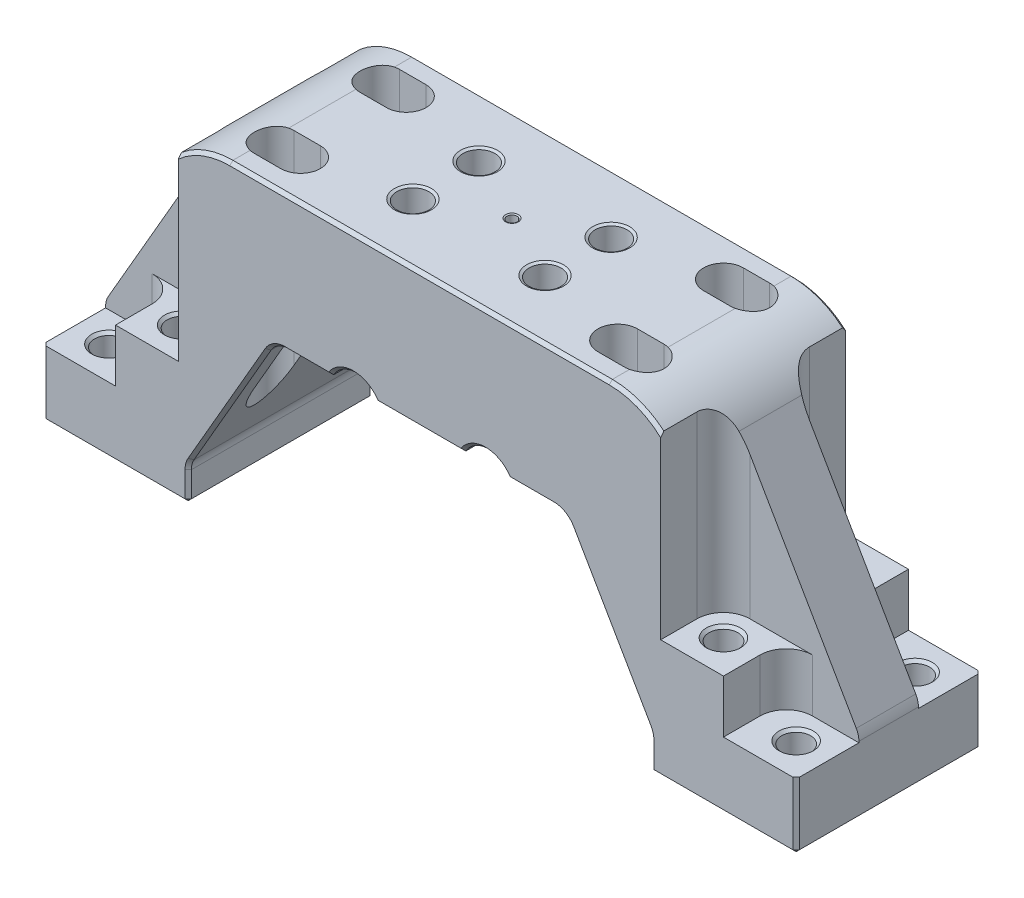
from build123d import *

# Parameters (mm, degrees)
EXTRUDE1_DEPTH                              = 44.45
FILLET1_R                                   = 38.1
FILLET2_R                                   = 9.525
FILLET5_R                                   = 9.525
EXTRUDE2_DEPTH                              = 25.4
FILLET3_R                                   = 3.175
EXTRUDE3_DEPTH                              = 95.25
EXTRUDE4_DEPTH                              = 25.4
F_1_2_CLEARANCE_HOLE1_AT_2_COUNT            = 2
F_1_2_CLEARANCE_HOLE1_AT_2_PITCH            = 260.35
F_1_2_CLEARANCE_HOLE1_AT_3_COUNT            = 2
F_1_2_CLEARANCE_HOLE1_AT_3_PITCH            = 266.548766645
F_1_2_CLEARANCE_HOLE1_AT_4_COUNT            = 2
F_1_2_CLEARANCE_HOLE1_AT_4_PITCH            = 57.15
F_1_2_CLEARANCE_HOLE2_AT_2_COUNT            = 2
F_1_2_CLEARANCE_HOLE2_AT_2_PITCH            = 57.15
F_1_2_CLEARANCE_HOLE2_AT_3_COUNT            = 2
F_1_2_CLEARANCE_HOLE2_AT_3_PITCH            = 335.10917997
F_1_2_CLEARANCE_HOLE2_AT_4_COUNT            = 2
F_1_2_CLEARANCE_HOLE2_AT_4_PITCH            = 330.2
TAPPED_HOLE_FOR_1_2_13_HELICOIL1_AT_2_COUNT = 2
TAPPED_HOLE_FOR_1_2_13_HELICOIL1_AT_2_PITCH = 63.5
TAPPED_HOLE_FOR_1_2_13_HELICOIL1_AT_3_COUNT = 2
TAPPED_HOLE_FOR_1_2_13_HELICOIL1_AT_3_PITCH = 70.995158286
TAPPED_HOLE_FOR_1_2_13_HELICOIL1_AT_4_COUNT = 2
TAPPED_HOLE_FOR_1_2_13_HELICOIL1_AT_4_PITCH = 31.75
EXTRUDE5_DEPTH                              = 153.4
SKETCH12_R                                  = 12.7
EXTRUDE6_DEPTH                              = 45.4500001
EXTRUDE6_DEPTH_BACK                         = 45.4500001
CHAMFER1_SIZE                               = 1.524


with BuildPart() as part:
    # Sketch1 → Extrude1 (new body, symmetric)
    with BuildSketch(Plane.XY):
        Polygon((-180.975, 0), (-111.125, 0), (-111.125, 16.208748909), (-70.036568425, 87.376), (70.036568425, 87.376), (111.125, 16.208748909), (111.125, 0), (180.975, 0), (180.975, 34.925), (113.150777127, 152.4), (-113.150777127, 152.4), (-180.975, 34.925), align=None)
    extrude(amount=EXTRUDE1_DEPTH, both=True)

    # Fillet1
    fillet1_edges = [part.edges().sort_by_distance(p)[0] for p in [
        (-113.150777127, 152.4, 0),
        (113.150777127, 152.4, 0),
    ]]
    fillet(fillet1_edges, radius=FILLET1_R)

    # Fillet2
    fillet2_edges = [part.edges().sort_by_distance(p)[0] for p in [
        (111.125, 16.208748909, 0),
        (70.036568425, 87.376, 0),
        (-70.036568425, 87.376, 0),
        (-111.125, 16.208748909, 0),
    ]]
    fillet(fillet2_edges, radius=FILLET2_R)

    # Fillet5
    fillet5_edges = [part.edges().sort_by_distance(p)[0] for p in [
        (-180.975, 34.925, 0),
        (180.975, 34.925, 0),
    ]]
    fillet(fillet5_edges, radius=FILLET5_R)

    # Sketch2 → Extrude2 (cut)
    with BuildSketch(Plane.XZ.offset(-87.376)):
        with BuildLine():
            Line((-47.625, 31.75), (47.625, 31.75))
            ThreePointArc((47.625, 31.75), (56.605256121, 28.030256121), (60.325, 19.05))
            Line((60.325, 19.05), (60.325, -19.05))
            ThreePointArc((60.325, -19.05), (56.605256121, -28.030256121), (47.625, -31.75))
            Line((47.625, -31.75), (-47.625, -31.75))
            ThreePointArc((-47.625, -31.75), (-56.605256121, -28.030256121), (-60.325, -19.05))
            Line((-60.325, -19.05), (-60.325, 19.05))
            ThreePointArc((-60.325, 19.05), (-56.605256121, 28.030256121), (-47.625, 31.75))
        make_face()
    extrude(amount=-EXTRUDE2_DEPTH, mode=Mode.SUBTRACT)

    # Fillet3
    fillet3_edges = [part.edges().sort_by_distance(p)[0] for p in [
        (-56.605256121, 112.776, 28.030256121),
        (0, 112.776, 31.75),
        (56.605256121, 112.776, 28.030256121),
        (60.325, 112.776, 0),
        (56.605256121, 112.776, -28.030256121),
        (0, 112.776, -31.75),
        (-56.605256121, 112.776, -28.030256121),
        (-60.325, 112.776, 0),
    ]]
    fillet(fillet3_edges, radius=FILLET3_R)

    # Sketch3 → Extrude3 (cut)
    with BuildSketch(Plane(origin=(0, 152.4, 0), x_dir=(1, 0, 0), z_dir=(0, 1, 0))):
        with BuildLine():
            Line((115.8875, 44.45), (180.975, 44.45))
            Line((180.975, 44.45), (180.975, 14.2875))
            Line((180.975, 14.2875), (128.5875, 14.2875))
            ThreePointArc((128.5875, 14.2875), (119.607243879, 18.007243879), (115.8875, 26.9875))
            Line((115.8875, 26.9875), (115.8875, 44.45))
        make_face()
        with BuildLine():
            Line((180.975, -44.45), (180.975, -14.2875))
            Line((180.975, -14.2875), (128.5875, -14.2875))
            ThreePointArc((128.5875, -14.2875), (119.607243879, -18.007243879), (115.8875, -26.9875))
            Line((115.8875, -26.9875), (115.8875, -44.45))
            Line((115.8875, -44.45), (180.975, -44.45))
        make_face()
        with BuildLine():
            Line((-115.8875, -44.45), (-180.975, -44.45))
            Line((-180.975, -44.45), (-180.975, -14.2875))
            Line((-180.975, -14.2875), (-128.5875, -14.2875))
            ThreePointArc((-128.5875, -14.2875), (-119.607243879, -18.007243879), (-115.8875, -26.9875))
            Line((-115.8875, -26.9875), (-115.8875, -44.45))
        make_face()
        with BuildLine():
            Line((-180.975, 44.45), (-180.975, 14.2875))
            Line((-180.975, 14.2875), (-128.5875, 14.2875))
            ThreePointArc((-128.5875, 14.2875), (-119.607243879, 18.007243879), (-115.8875, 26.9875))
            Line((-115.8875, 26.9875), (-115.8875, 44.45))
            Line((-115.8875, 44.45), (-180.975, 44.45))
        make_face()
    extrude(amount=-EXTRUDE3_DEPTH, mode=Mode.SUBTRACT)

    # Sketch4 → Extrude4 (cut)
    with BuildSketch(Plane(origin=(0, 57.15, 0), x_dir=(1, 0, 0), z_dir=(0, 1, 0))):
        with BuildLine():
            Line((180.975, 44.45), (146.05, 44.45))
            Line((146.05, 44.45), (146.05, 26.9875))
            ThreePointArc((146.05, 26.9875), (149.769743879, 18.007243879), (158.75, 14.2875))
            Line((158.75, 14.2875), (180.975, 14.2875))
            Line((180.975, 14.2875), (180.975, 44.45))
        make_face()
        with BuildLine():
            Line((146.05, -44.45), (146.05, -26.9875))
            ThreePointArc((146.05, -26.9875), (149.769743879, -18.007243879), (158.75, -14.2875))
            Line((158.75, -14.2875), (180.975, -14.2875))
            Line((180.975, -14.2875), (180.975, -44.45))
            Line((180.975, -44.45), (146.05, -44.45))
        make_face()
        with BuildLine():
            Line((-180.975, -44.45), (-146.05, -44.45))
            Line((-146.05, -44.45), (-146.05, -26.9875))
            ThreePointArc((-146.05, -26.9875), (-149.769743879, -18.007243879), (-158.75, -14.2875))
            Line((-158.75, -14.2875), (-180.975, -14.2875))
            Line((-180.975, -14.2875), (-180.975, -44.45))
        make_face()
        with BuildLine():
            Line((-146.05, 44.45), (-146.05, 26.9875))
            ThreePointArc((-146.05, 26.9875), (-149.769743879, 18.007243879), (-158.75, 14.2875))
            Line((-158.75, 14.2875), (-180.975, 14.2875))
            Line((-180.975, 14.2875), (-180.975, 44.45))
            Line((-180.975, 44.45), (-146.05, 44.45))
        make_face()
    extrude(amount=-EXTRUDE4_DEPTH, mode=Mode.SUBTRACT)

    # Sketch5 → 1/2 Clearance Hole1 (revolve, cut)
    with BuildSketch(Plane(origin=(130.175, 57.15, -28.575), x_dir=(0, 0, 1), z_dir=(1, 0, 0))):
        Polygon((0, 0), (0, 57.15), (8.255, 57.15), (6.94563, 55.84063), (6.94563, 1.30937), (8.255, 0), align=None)
    f_1_2_clearance_hole1 = revolve(axis=Axis((130.175, 63.5, -28.575), (0, -1, 0)), mode=Mode.SUBTRACT)

    # 1/2 Clearance Hole1 at 2: 1/2 Clearance Hole1 ×2
    with Locations(*[(-i * F_1_2_CLEARANCE_HOLE1_AT_2_PITCH, 0, 0) for i in range(1, F_1_2_CLEARANCE_HOLE1_AT_2_COUNT)]):
        add(f_1_2_clearance_hole1, mode=Mode.SUBTRACT)

    # 1/2 Clearance Hole1 at 3: 1/2 Clearance Hole1 ×2
    with Locations(*[Vector(-0.976744343, 0, 0.214407295) * (i * F_1_2_CLEARANCE_HOLE1_AT_3_PITCH) for i in range(1, F_1_2_CLEARANCE_HOLE1_AT_3_COUNT)]):
        add(f_1_2_clearance_hole1, mode=Mode.SUBTRACT)

    # 1/2 Clearance Hole1 at 4: 1/2 Clearance Hole1 ×2
    with Locations(*[(0, 0, i * F_1_2_CLEARANCE_HOLE1_AT_4_PITCH) for i in range(1, F_1_2_CLEARANCE_HOLE1_AT_4_COUNT)]):
        add(f_1_2_clearance_hole1, mode=Mode.SUBTRACT)

    # Sketch7 → 1/2 Clearance Hole2 (revolve, cut)
    with BuildSketch(Plane(origin=(165.1, 31.75, -28.575), x_dir=(0, 0, 1), z_dir=(1, 0, 0))):
        Polygon((0, 0), (0, 31.75), (8.255, 31.75), (6.94563, 30.44063), (6.94563, 1.30937), (8.255, 0), align=None)
    f_1_2_clearance_hole2 = revolve(axis=Axis((165.1, 38.1, -28.575), (0, -1, 0)), mode=Mode.SUBTRACT)

    # 1/2 Clearance Hole2 at 2: 1/2 Clearance Hole2 ×2
    with Locations(*[(0, 0, i * F_1_2_CLEARANCE_HOLE2_AT_2_PITCH) for i in range(1, F_1_2_CLEARANCE_HOLE2_AT_2_COUNT)]):
        add(f_1_2_clearance_hole2, mode=Mode.SUBTRACT)

    # 1/2 Clearance Hole2 at 3: 1/2 Clearance Hole2 ×2
    with Locations(*[Vector(-0.985350506, 0, 0.170541434) * (i * F_1_2_CLEARANCE_HOLE2_AT_3_PITCH) for i in range(1, F_1_2_CLEARANCE_HOLE2_AT_3_COUNT)]):
        add(f_1_2_clearance_hole2, mode=Mode.SUBTRACT)

    # 1/2 Clearance Hole2 at 4: 1/2 Clearance Hole2 ×2
    with Locations(*[(-i * F_1_2_CLEARANCE_HOLE2_AT_4_PITCH, 0, 0) for i in range(1, F_1_2_CLEARANCE_HOLE2_AT_4_COUNT)]):
        add(f_1_2_clearance_hole2, mode=Mode.SUBTRACT)

    # Sketch9 → Tapped Hole for 1/2-13 Helicoil1 (revolve, cut)
    with BuildSketch(Plane(origin=(-31.75, 152.4, -15.875), x_dir=(0, 0, 1), z_dir=(1, 0, 0))):
        Polygon((0, 0), (0, 39.624), (6.54812, 39.624), (6.54812, 29.972), (7.67334, 29.972), (7.67334, 0.702438979), (8.89, 0), align=None)
    tapped_hole_for_1_2_13_helicoil1 = revolve(axis=Axis((-31.75, 158.75, -15.875), (0, -1, 0)), mode=Mode.SUBTRACT)

    # Tapped Hole for 1/2-13 Helicoil1 at 2: Tapped Hole for 1/2-13 Helicoil1 ×2
    with Locations(*[(i * TAPPED_HOLE_FOR_1_2_13_HELICOIL1_AT_2_PITCH, 0, 0) for i in range(1, TAPPED_HOLE_FOR_1_2_13_HELICOIL1_AT_2_COUNT)]):
        add(tapped_hole_for_1_2_13_helicoil1, mode=Mode.SUBTRACT)

    # Tapped Hole for 1/2-13 Helicoil1 at 3: Tapped Hole for 1/2-13 Helicoil1 ×2
    with Locations(*[Vector(0.894427191, 0, 0.447213595) * (i * TAPPED_HOLE_FOR_1_2_13_HELICOIL1_AT_3_PITCH) for i in range(1, TAPPED_HOLE_FOR_1_2_13_HELICOIL1_AT_3_COUNT)]):
        add(tapped_hole_for_1_2_13_helicoil1, mode=Mode.SUBTRACT)

    # Tapped Hole for 1/2-13 Helicoil1 at 4: Tapped Hole for 1/2-13 Helicoil1 ×2
    with Locations(*[(0, 0, i * TAPPED_HOLE_FOR_1_2_13_HELICOIL1_AT_4_PITCH) for i in range(1, TAPPED_HOLE_FOR_1_2_13_HELICOIL1_AT_4_COUNT)]):
        add(tapped_hole_for_1_2_13_helicoil1, mode=Mode.SUBTRACT)

    # Sketch11 → Extrude5 (cut, through all)
    with BuildSketch(Plane(origin=(0, 152.4, 0), x_dir=(1, 0, 0), z_dir=(0, 1, 0))):
        with BuildLine():
            Line((-88.9, 34.925), (-76.2, 34.925))
            ThreePointArc((-76.2, 34.925), (-66.675, 25.4), (-76.2, 15.875))
            Line((-76.2, 15.875), (-88.9, 15.875))
            ThreePointArc((-88.9, 15.875), (-98.425, 25.4), (-88.9, 34.925))
        make_face()
        with BuildLine():
            Line((-88.9, -15.875), (-76.2, -15.875))
            ThreePointArc((-76.2, -15.875), (-66.675, -25.4), (-76.2, -34.925))
            Line((-76.2, -34.925), (-88.9, -34.925))
            ThreePointArc((-88.9, -34.925), (-98.425, -25.4), (-88.9, -15.875))
        make_face()
        with BuildLine():
            Line((76.2, 34.925), (88.9, 34.925))
            ThreePointArc((88.9, 34.925), (98.425, 25.4), (88.9, 15.875))
            Line((88.9, 15.875), (76.2, 15.875))
            ThreePointArc((76.2, 15.875), (66.675, 25.4), (76.2, 34.925))
        make_face()
        with BuildLine():
            Line((76.2, -15.875), (88.9, -15.875))
            ThreePointArc((88.9, -15.875), (98.425, -25.4), (88.9, -34.925))
            Line((88.9, -34.925), (76.2, -34.925))
            ThreePointArc((76.2, -34.925), (66.675, -25.4), (76.2, -15.875))
        make_face()
    extrude(amount=-EXTRUDE5_DEPTH, mode=Mode.SUBTRACT)

    # Sketch12 → Extrude6 (cut, two sides)
    with BuildSketch(Plane.XY) as extrude6_sk:
        with Locations((-31.75, 81.026)):
            Circle(SKETCH12_R)
        with Locations((31.75, 81.026)):
            Circle(SKETCH12_R)
    extrude(amount=EXTRUDE6_DEPTH, mode=Mode.SUBTRACT)
    extrude(extrude6_sk.sketch, amount=-EXTRUDE6_DEPTH_BACK, mode=Mode.SUBTRACT)

    # Chamfer1
    chamfer1_edges = [part.edges().sort_by_distance(p)[0] for p in [
        (-111.125, 6.828266425, 44.45),
        (180.975, 15.875, -44.45),
        (146.05, 0, -44.45),
        (-111.125, 6.828266425, -44.45),
        (-146.05, 0, -44.45),
        (104.334498541, 150.047410955, 44.45),
        (-104.334498541, 150.047410955, -44.45),
        (180.975, 0, 0),
        (111.125, 0, 0),
        (-111.125, 0, 0),
        (-180.975, 0, 0),
        (146.05, 0, 44.45),
        (-180.975, 15.875, 44.45),
        (-180.975, 15.875, -44.45),
        (180.975, 15.875, 44.45),
        (0, 152.4, -44.45),
        (0, 152.4, 44.45),
        (104.334498541, 150.047410955, -44.45),
        (-104.334498541, 150.047410955, 44.45),
        (111.125, 6.828266425, -44.45),
        (111.125, 6.828266425, 44.45),
        (91.317545527, 50.516266425, -44.45),
        (91.317545527, 50.516266425, 44.45),
        (0, 87.376, -31.75),
        (-31.75, 93.726, -31.75),
        (-45.186761314, 87.376, 31.75),
        (0, 87.376, -44.45),
        (0, 87.376, 44.45),
        (-31.75, 93.726, 44.45),
        (-31.75, 93.726, 31.75),
        (-31.75, 93.726, -44.45),
        (-53.642914869, 87.376, -44.45),
        (45.186761314, 87.376, -31.75),
        (31.75, 93.726, -31.75),
        (-53.642914869, 87.376, 44.45),
        (0, 87.376, 31.75),
        (53.642914869, 87.376, -44.45),
        (53.642914869, 87.376, 44.45),
        (31.75, 93.726, 44.45),
        (31.75, 93.726, 31.75),
        (31.75, 93.726, -44.45),
        (-91.317545527, 50.516266425, -44.45),
        (-91.317545527, 50.516266425, 44.45),
        (110.800443495, 16.121784255, -44.45),
        (110.800443495, 16.121784255, 44.45),
        (69.299807111, 86.099891971, -44.45),
        (69.299807111, 86.099891971, 44.45),
        (-69.299807111, 86.099891971, -44.45),
        (-69.299807111, 86.099891971, 44.45),
        (-110.800443495, 16.121784255, -44.45),
        (-110.800443495, 16.121784255, 44.45),
        (-146.05, 0, 44.45),
        (-56.605256121, 87.376, 28.030256121),
        (-60.325, 87.376, 0),
        (-56.605256121, 87.376, -28.030256121),
        (-45.186761314, 87.376, -31.75),
        (56.605256121, 87.376, -28.030256121),
        (60.325, 87.376, 0),
        (56.605256121, 87.376, 28.030256121),
        (45.186761314, 87.376, 31.75),
    ]]
    chamfer(chamfer1_edges, length=CHAMFER1_SIZE)

    # Sketch19 → #10-32 Tapped Hole1 (revolve, cut)
    with BuildSketch(Plane(origin=(0, 152.4, 0), x_dir=(0, 0, 1), z_dir=(1, 0, 0))):
        Polygon((0, 0), (0, 20.263317848), (2.0193, 19.05), (2.0193, 11.43), (2.413, 11.43), (2.413, 0.366617421), (3.048, 0), align=None)
    revolve(axis=Axis((0, 158.75, 0), (0, -1, 0)), mode=Mode.SUBTRACT)


solid = part.part
